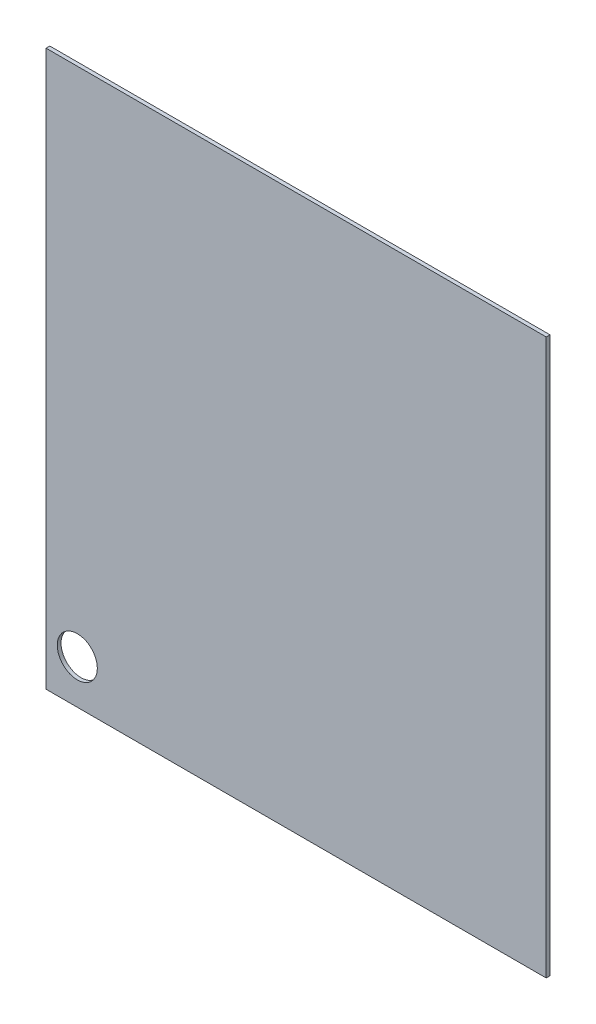
from build123d import *

# Parameters (mm, degrees)
SKETCH1_W           = 400
SKETCH1_H           = 452
BOSS_EXTRUDE1_DEPTH = 3
SKETCH4_R           = 16
CUT_EXTRUDE2_DEPTH  = 10
SKETCH5_W           = 400
SKETCH5_H           = 8
CUT_EXTRUDE3_DEPTH  = 4


with BuildPart() as part:
    # Sketch1 → Boss-Extrude1 (new body)
    with BuildSketch(Plane.XY):
        with Locations((200, 226)):
            Rectangle(SKETCH1_W, SKETCH1_H)
    extrude(amount=BOSS_EXTRUDE1_DEPTH)

    # Sketch4 → Cut-Extrude2 (cut)
    with BuildSketch(Plane.XY.offset(3)):
        with Locations((25, 35)):
            Circle(SKETCH4_R)
    extrude(amount=-CUT_EXTRUDE2_DEPTH, mode=Mode.SUBTRACT)

    # Sketch5 → Cut-Extrude3 (cut, through all)
    with BuildSketch(Plane(origin=(0, 0, 0), x_dir=(-1, 0, 0), z_dir=(0, 0, -1))):
        with Locations((-200, 448)):
            Rectangle(SKETCH5_W, SKETCH5_H)
    extrude(amount=-CUT_EXTRUDE3_DEPTH, mode=Mode.SUBTRACT)


solid = part.part
